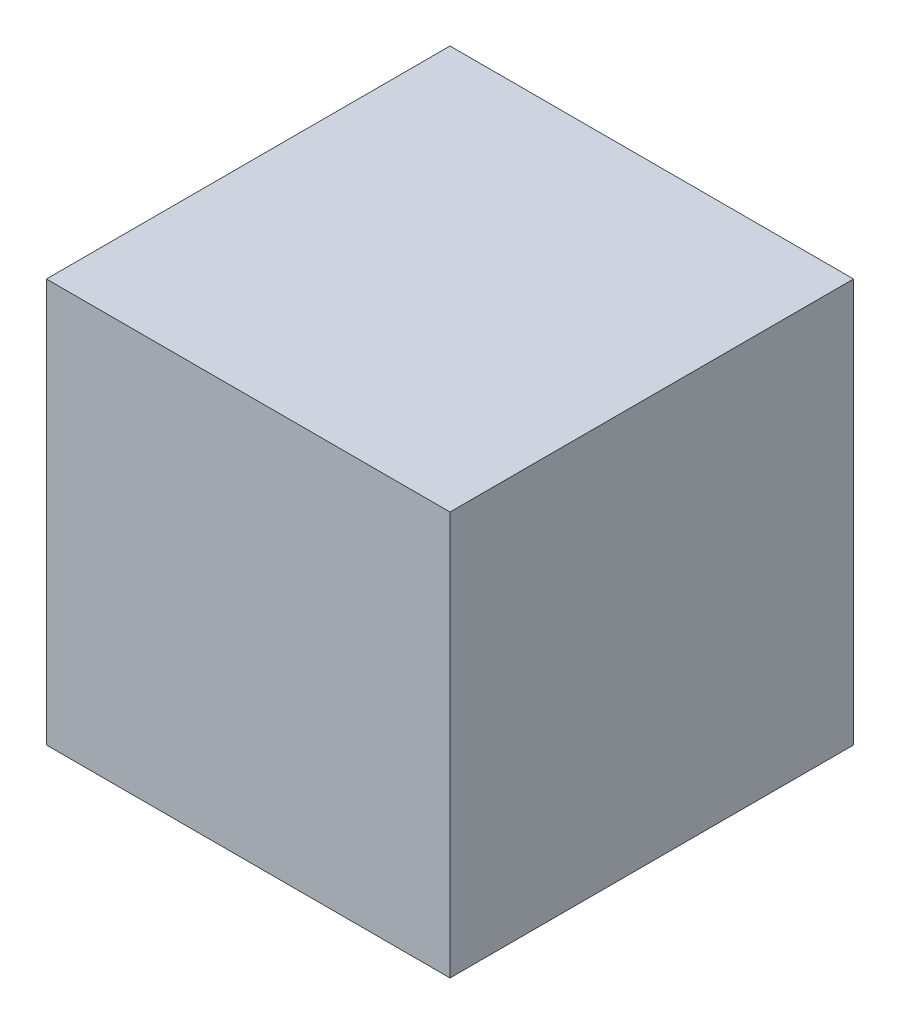
from build123d import *

# Parameters (mm, degrees)
SKETCH1_W           = 10
SKETCH1_H           = 10
BOSS_EXTRUDE1_DEPTH = 10


with BuildPart() as part:
    # Sketch1 → Boss-Extrude1 (new body)
    with BuildSketch(Plane.XY):
        with Locations((5, 5)):
            Rectangle(SKETCH1_W, SKETCH1_H)
    extrude(amount=BOSS_EXTRUDE1_DEPTH)


solid = part.part
